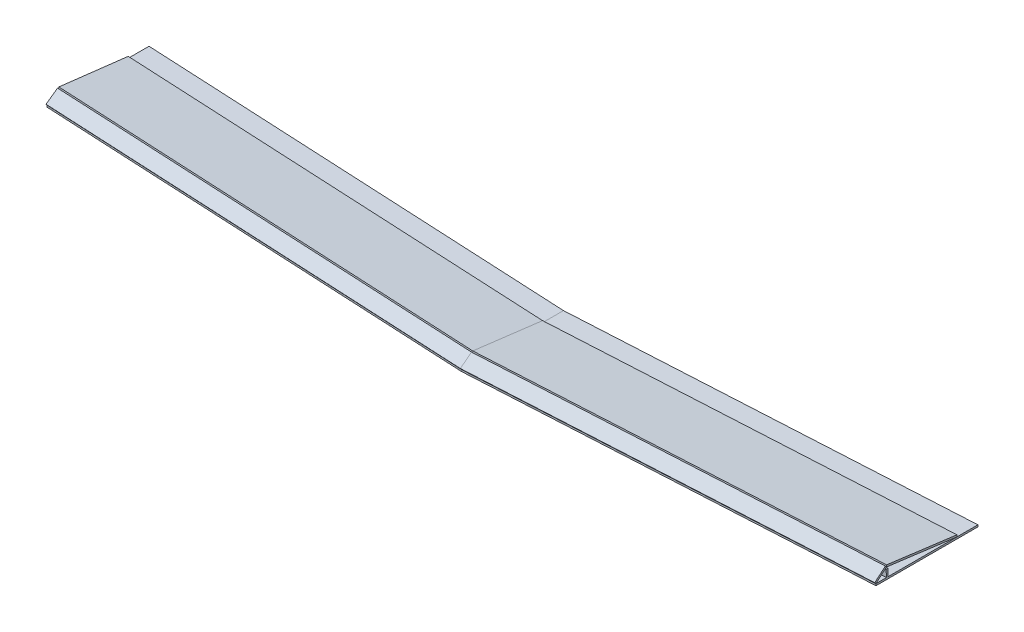
from build123d import *

# Parameters (mm, degrees)
BOSS_EXTRUDE4_DEPTH   = 749.3
BOSS_EXTRUDE4_2_DEPTH = 749.3
BOSS_EXTRUDE4_3_DEPTH = 749.3
SKETCH1_3_W           = 3.175
SKETCH1_3_H           = 12.7
BOSS_EXTRUDE6_DEPTH   = 749.3


with BuildPart() as part:
    # Sketch1 → Boss-Extrude4 (new body)
    with BuildSketch(Plane(origin=(0, 0, 0), x_dir=(0, 0, -1), z_dir=(0.9986295347545743, 0.05233595624293715, 0))):
        Polygon((0, 3.175), (0, 0), (184.15, 0), (184.15, 3.175), (146.05, 3.175), (22.225, 3.175), (22.225, 15.875), (19.05, 15.875), (19.05, 3.175), align=None)
    extrude(amount=BOSS_EXTRUDE4_DEPTH)


with BuildPart() as body_2:
    # Sketch1 → Boss-Extrude4 2 (new body)
    with BuildSketch(Plane(origin=(0, 0, 0), x_dir=(0, 0, -1), z_dir=(0.9986295347545743, 0.05233595624293715, 0))):
        Polygon((-1.95459219, 5.677038043), (0, 3.175), (20.016304348, 18.81173752), (18.061712158, 21.313775563), align=None)
    extrude(amount=BOSS_EXTRUDE4_2_DEPTH)


with BuildPart() as body_3:
    # Sketch1 → Boss-Extrude4 3 (new body)
    with BuildSketch(Plane(origin=(0, 0, 0), x_dir=(0, 0, -1), z_dir=(0.9986295347545743, 0.05233595624293715, 0))):
        Polygon((20.407222786, 21.962579911), (20.016304348, 18.81173752), (146.05, 3.175), (146.440918438, 6.325842391), align=None)
    extrude(amount=BOSS_EXTRUDE4_3_DEPTH)


with BuildPart() as body_4:
    # Sketch1_3 → Boss-Extrude6 (new body)
    with BuildSketch(Plane(origin=(0, 0, 0), x_dir=(0, 0, -1), z_dir=(0.9986295347545743, 0.05233595624293715, 0))):
        with Locations((20.6375, 9.525)):
            Rectangle(SKETCH1_3_W, SKETCH1_3_H)
    extrude(amount=BOSS_EXTRUDE6_DEPTH)


with BuildPart() as body_5:
    # Mirror5: mirrored copy
    add(body_2.part.mirror(Plane(origin=(0, 0, 0), x_dir=(0, 0, 1), z_dir=(1, 0, 0))))


with BuildPart() as body_6:
    # Mirror5 2: mirrored copy
    add(part.part.mirror(Plane(origin=(0, 0, 0), x_dir=(0, 0, 1), z_dir=(1, 0, 0))))


with BuildPart() as body_7:
    # Mirror5 3: mirrored copy
    add(body_4.part.mirror(Plane(origin=(0, 0, 0), x_dir=(0, 0, 1), z_dir=(1, 0, 0))))


with BuildPart() as body_8:
    # Mirror5 4: mirrored copy
    add(body_3.part.mirror(Plane(origin=(0, 0, 0), x_dir=(0, 0, 1), z_dir=(1, 0, 0))))


solid = Compound([part.part, body_2.part, body_3.part, body_4.part, body_5.part, body_6.part, body_7.part, body_8.part])
